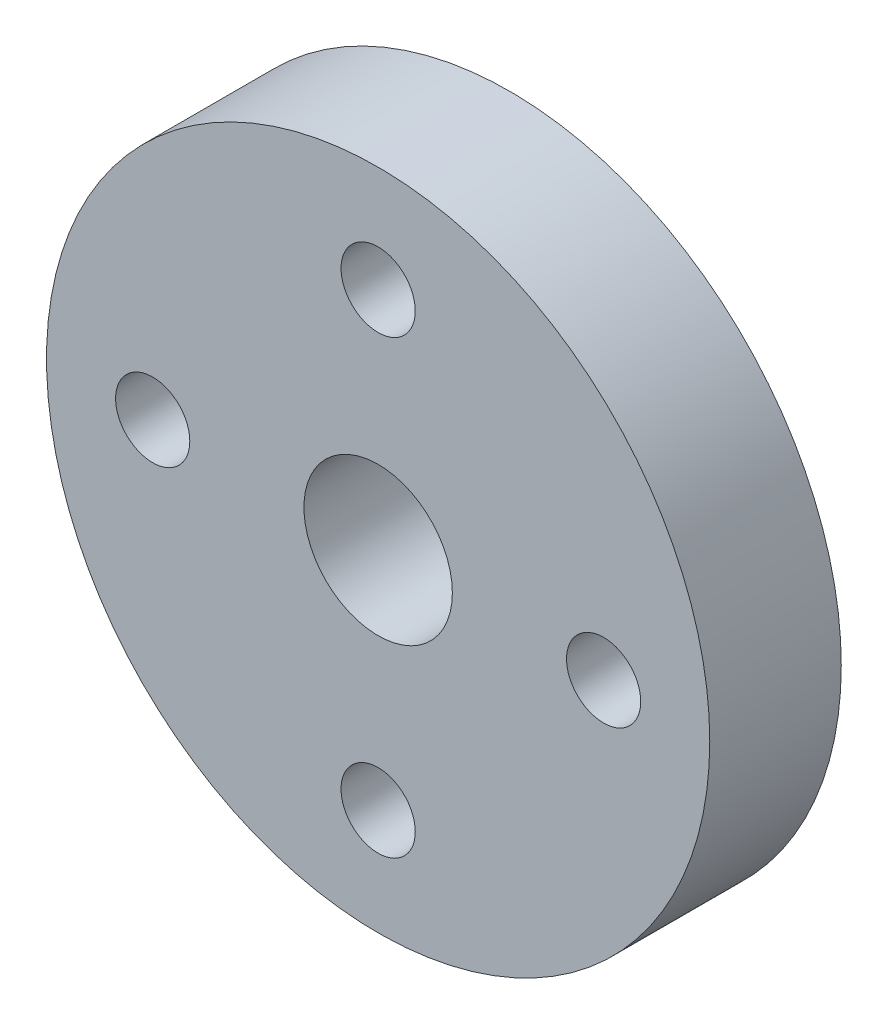
from build123d import *

# Parameters (mm, degrees)
SKETCH1_R           = 17.65
SKETCH1_R_2         = 3.95
SKETCH1_R_3         = 1.975
BOSS_EXTRUDE1_DEPTH = 7


with BuildPart() as part:
    # Sketch1 → Boss-Extrude1 (new body)
    with BuildSketch(Plane.XY):
        Circle(SKETCH1_R)
        Circle(SKETCH1_R_2, mode=Mode.SUBTRACT)
        with Locations((0, 12)):
            Circle(SKETCH1_R_3, mode=Mode.SUBTRACT)
        with Locations((12, 0)):
            Circle(SKETCH1_R_3, mode=Mode.SUBTRACT)
        with Locations((0, -12)):
            Circle(SKETCH1_R_3, mode=Mode.SUBTRACT)
        with Locations((-12, 0)):
            Circle(SKETCH1_R_3, mode=Mode.SUBTRACT)
    extrude(amount=BOSS_EXTRUDE1_DEPTH)


solid = part.part
